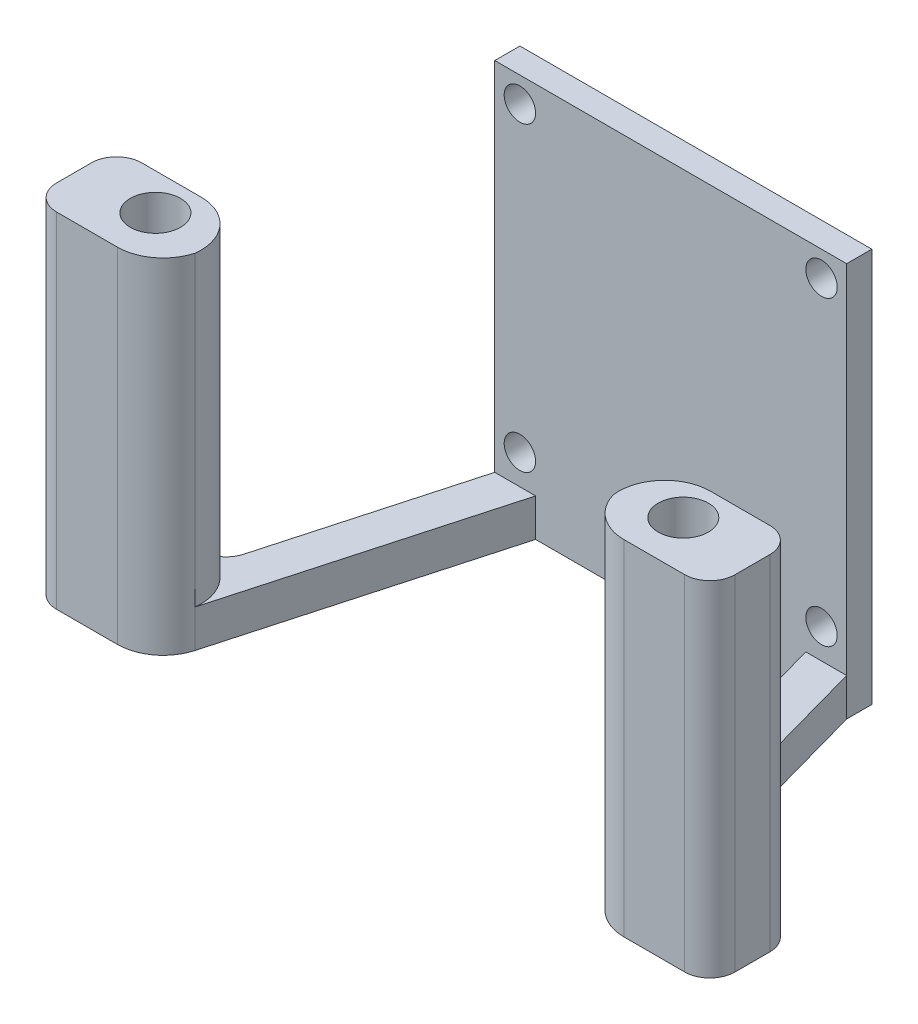
from build123d import *

# Parameters (mm, degrees)
SKETCH_1_W          = 28
SKETCH_1_H          = 31.376198505
SKETCH_1_R          = 1.25
EXTRUDE_1_DEPTH     = 4
SKETCH_4_R          = 2
EXTRUDE_3_DEPTH     = 3
SKETCH_6_R          = 2
EXTRUDE_4_DEPTH     = 24.38
SKETCH_7_W          = 28
SKETCH_7_H          = 2
CUT_EXTRUDE_1_DEPTH = 72


with BuildPart() as part:
    # 草图1 → 凸台-拉伸1 (new body)
    with BuildSketch(Plane.XY):
        with Locations((0, -1.688099253)):
            Rectangle(SKETCH_1_W, SKETCH_1_H)
        with Locations((-12, -12)):
            Circle(SKETCH_1_R, mode=Mode.SUBTRACT)
        with Locations((-12, 12)):
            Circle(SKETCH_1_R, mode=Mode.SUBTRACT)
        with Locations((12, 12)):
            Circle(SKETCH_1_R, mode=Mode.SUBTRACT)
        with Locations((12, -12)):
            Circle(SKETCH_1_R, mode=Mode.SUBTRACT)
    extrude(amount=EXTRUDE_1_DEPTH)

    # 草图4 → 凸台-拉伸3 (add)
    with BuildSketch(Plane(origin=(0, -17.376198505, 0), x_dir=(1, 0, 0), z_dir=(0, 1, 0))):
        with BuildLine():
            Line((-10.75, -4), (-16.6423045, -25.198978267))
            ThreePointArc((-16.6423045, -25.198978267), (-17.942800458, -27.122401454), (-20.139772651, -27.873507091))
            Line((-20.139772651, -27.873507091), (-24.991319672, -27.873507091))
            ThreePointArc((-24.991319672, -27.873507091), (-26.405533234, -27.287720654), (-26.991319672, -25.873507091))
            Line((-26.991319672, -25.873507091), (-26.991319672, -23.098090883))
            ThreePointArc((-26.991319672, -23.098090883), (-26.405533234, -21.68387732), (-24.991319672, -21.098090883))
            Line((-24.991319672, -21.098090883), (-20.272369191, -21.098090883))
            ThreePointArc((-20.272369191, -21.098090883), (-19.062245191, -20.690447597), (-18.345420115, -19.633690786))
            Line((-18.345420115, -19.633690786), (-14, -4))
            Line((-14, -4), (-10.75, -4))
        make_face()
        with Locations((-21, -24)):
            Circle(SKETCH_4_R, mode=Mode.SUBTRACT)
    extrude_3 = extrude(amount=EXTRUDE_3_DEPTH)

    # 草图6 → 凸台-拉伸4 (add)
    with BuildSketch(Plane(origin=(0, -14.376198505, 0), x_dir=(1, 0, 0), z_dir=(0, 1, 0))):
        with BuildLine():
            ThreePointArc((-20.272369191, -21.098090883), (-17.534000745, -22.331206649), (-16.6423045, -25.198978267))
            ThreePointArc((-16.6423045, -25.198978267), (-17.942800458, -27.122401454), (-20.139772651, -27.873507091))
            Line((-20.139772651, -27.873507091), (-24.991319672, -27.873507091))
            ThreePointArc((-24.991319672, -27.873507091), (-26.405533234, -27.287720654), (-26.991319672, -25.873507091))
            Line((-26.991319672, -25.873507091), (-26.991319672, -23.098090883))
            ThreePointArc((-26.991319672, -23.098090883), (-26.405533234, -21.68387732), (-24.991319672, -21.098090883))
            Line((-24.991319672, -21.098090883), (-20.272369191, -21.098090883))
        make_face()
        with Locations((-21, -24)):
            Circle(SKETCH_6_R, mode=Mode.SUBTRACT)
    extrude_4 = extrude(amount=EXTRUDE_4_DEPTH)

    # 镜向1: 凸台-拉伸3, 凸台-拉伸4 across plane
    add(extrude_3.mirror(Plane(origin=(0, 0, 0), x_dir=(0, 0, 1), z_dir=(1, 0, 0))))
    add(extrude_4.mirror(Plane(origin=(0, 0, 0), x_dir=(0, 0, 1), z_dir=(1, 0, 0))))

    # 草图7 → 切除-拉伸1 (cut)
    with BuildSketch(Plane(origin=(0, 14, 0), x_dir=(1, 0, 0), z_dir=(0, 1, 0))):
        with Locations((0, -1)):
            Rectangle(SKETCH_7_W, SKETCH_7_H)
    extrude(amount=-CUT_EXTRUDE_1_DEPTH, mode=Mode.SUBTRACT)


solid = part.part
